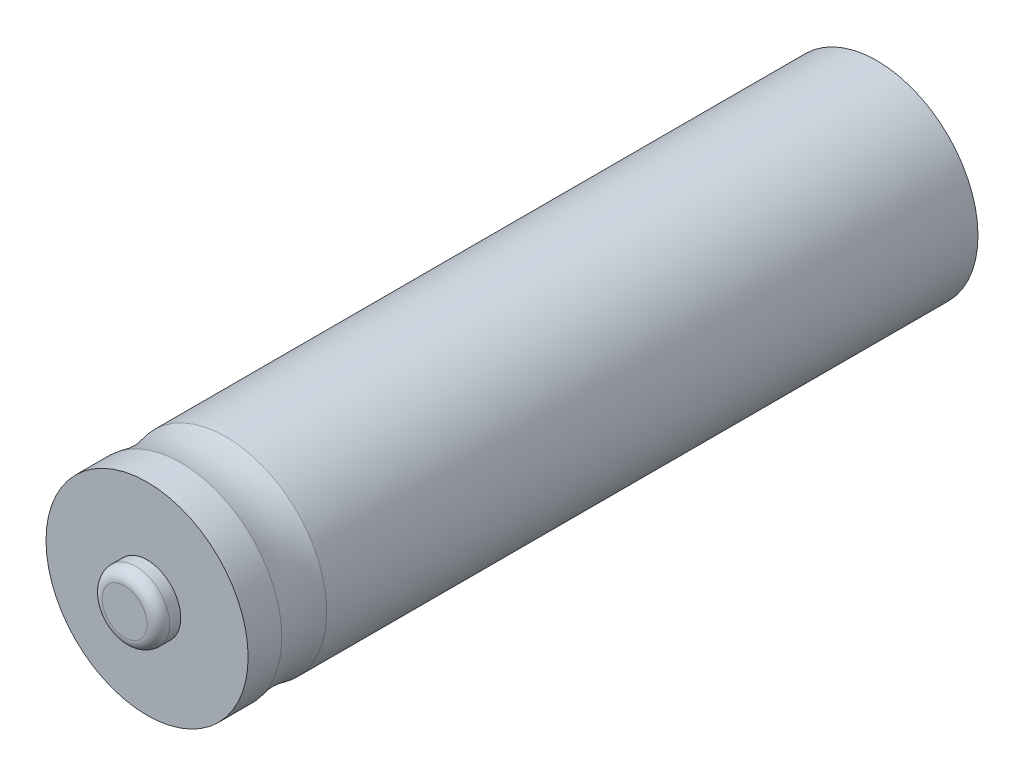
from build123d import *

# Parameters (mm, degrees)
ESBO_O1_R                = 9
RESSALTO_EXTRUS_O1_DEPTH = 32.5
ESBO_O2_R                = 3
RESSALTO_EXTRUS_O2_DEPTH = 2
FILETE1_R                = 1
ESBO_O4_R                = 5.5
RESSALTO_EXTRUS_O3_DEPTH = 0.4


with BuildPart() as part:
    # Esboço1 → Ressalto-extrusão1 (new body, symmetric)
    with BuildSketch(Plane.XY):
        Circle(ESBO_O1_R)
    extrude(amount=RESSALTO_EXTRUS_O1_DEPTH, both=True)

    # Esboço2 → Ressalto-extrusão2 (add)
    with BuildSketch(Plane.XY.offset(32.5)):
        Circle(ESBO_O2_R)
    extrude(amount=RESSALTO_EXTRUS_O2_DEPTH)

    # Filete1
    filete1_edges = [part.edges().sort_by_distance(p)[0] for p in [
        (-3, 0, 34.5),
    ]]
    fillet(filete1_edges, radius=FILETE1_R)

    # Esboço3 → Corte-Revolução1 (revolve, cut)
    with BuildSketch(Plane(origin=(0, 0, 0), x_dir=(0, 0, -1), z_dir=(1, 0, 0))):
        with BuildLine():
            Line((-29.5, 9), (-25.5, 9))
            ThreePointArc((-25.5, 9), (-27.5, 8.73940243), (-29.5, 9))
        make_face()
    revolve(axis=Axis((0, 0, 34.5), (0, 0, 1)), mode=Mode.SUBTRACT)

    # Esboço4 → Ressalto-extrusão3 (add)
    with BuildSketch(Plane(origin=(0, 0, -32.5), x_dir=(-1, 0, 0), z_dir=(0, 0, -1))):
        Circle(ESBO_O4_R)
    extrude(amount=RESSALTO_EXTRUS_O3_DEPTH)


solid = part.part
